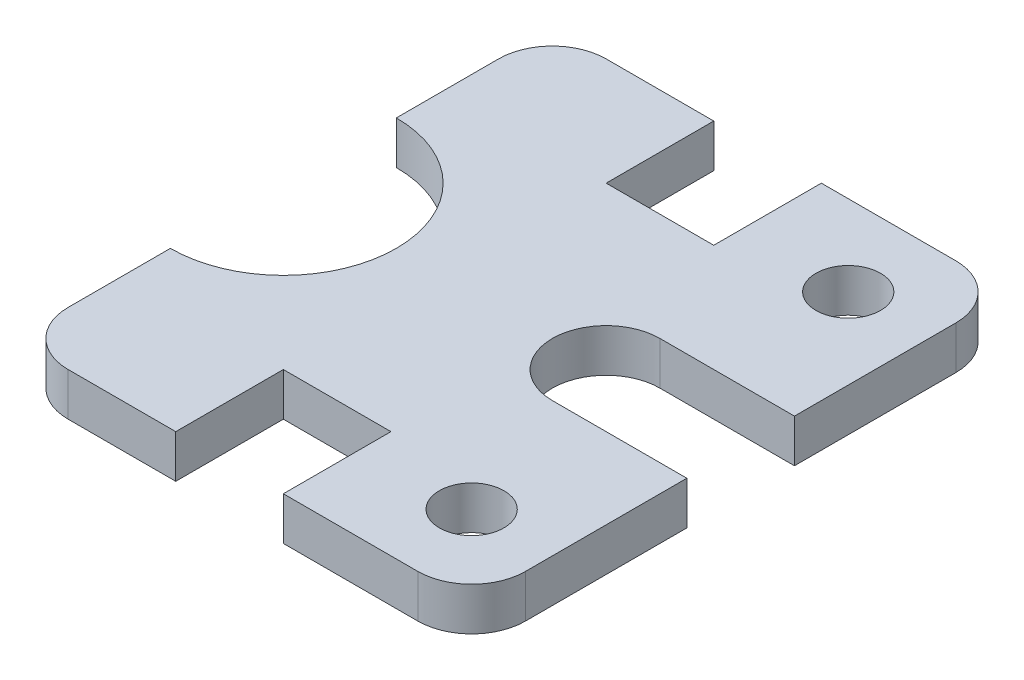
from build123d import *

# Parameters (mm, degrees)
SKETCH1_R           = 6
BOSS_EXTRUDE1_DEPTH = 8


with BuildPart() as part:
    # Sketch1 → Boss-Extrude1 (new body)
    with BuildSketch(Plane(origin=(0, 0, 0), x_dir=(1, 0, 0), z_dir=(0, 1, 0))):
        with BuildLine():
            Line((0, 0), (25, 0))
            Line((25, 0), (25, 30))
            ThreePointArc((25, 30), (22.071067812, 37.071067812), (15, 40))
            Line((15, 40), (-10, 40))
            Line((-10, 40), (-10, 20))
            Line((-10, 20), (-30, 20))
            Line((-30, 20), (-30, 40))
            Line((-30, 40), (-50, 40))
            ThreePointArc((-50, 40), (-57.071067812, 37.071067812), (-60, 30))
            Line((-60, 30), (-60, 11))
            ThreePointArc((-60, 11), (-39, -10), (-60, -31))
            Line((-60, -31), (-60, -50))
            ThreePointArc((-60, -50), (-57.071067812, -57.071067812), (-50, -60))
            Line((-50, -60), (-30, -60))
            Line((-30, -60), (-30, -40))
            Line((-30, -40), (-10, -40))
            Line((-10, -40), (-10, -60))
            Line((-10, -60), (15, -60))
            ThreePointArc((15, -60), (22.071067812, -57.071067812), (25, -50))
            Line((25, -50), (25, -20))
            Line((25, -20), (0, -20))
            ThreePointArc((0, -20), (-10, -10), (0, 0))
        make_face()
        with Locations((10, -45)):
            Circle(SKETCH1_R, mode=Mode.SUBTRACT)
        with Locations((10, 25)):
            Circle(SKETCH1_R, mode=Mode.SUBTRACT)
    extrude(amount=BOSS_EXTRUDE1_DEPTH)


solid = part.part
